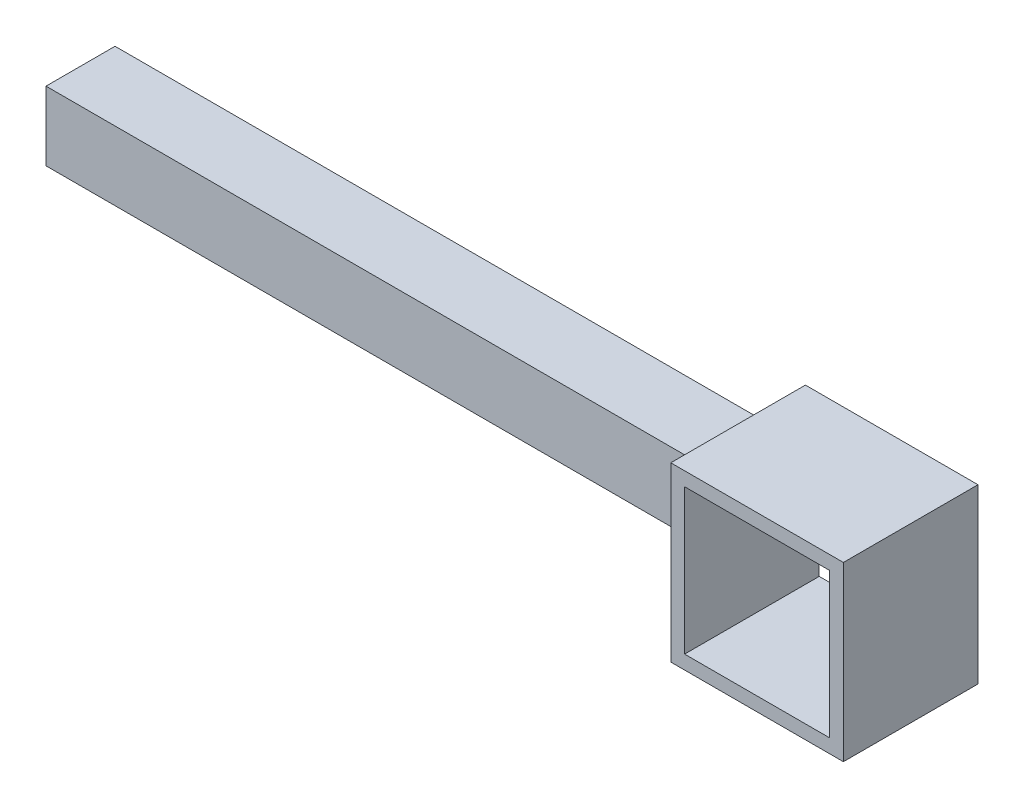
from build123d import *

# Parameters (mm, degrees)
ESQUISSE1_W             = 200
ESQUISSE1_H             = 20
ESQUISSE1_W_2           = 42
ESQUISSE1_H_2           = 42
BOSS_EXTRU_1_DEPTH      = 39
ESQUISSE2_W             = 200
ESQUISSE2_H             = 20
ENL_V_MAT_EXTRU_1_DEPTH = 19
ESQUISSE3_W             = 204
ESQUISSE3_H             = 10
ENL_V_MAT_EXTRU_3_DEPTH = 5


with BuildPart() as part:
    # Esquisse1 → Boss.-Extru.1 (new body)
    with BuildSketch(Plane.XY):
        with Locations((100, -10)):
            Rectangle(ESQUISSE1_W, ESQUISSE1_H)
        Polygon((200, 15), (200, 0), (200, -20), (200, -35), (250, -35), (250, 15), align=None)
        with Locations((225, -10)):
            Rectangle(ESQUISSE1_W_2, ESQUISSE1_H_2, mode=Mode.SUBTRACT)
    extrude(amount=BOSS_EXTRU_1_DEPTH)

    # Esquisse2 → Enlèv. mat.-Extru.1 (cut)
    with BuildSketch(Plane.XY.offset(39)):
        with Locations((100, -10)):
            Rectangle(ESQUISSE2_W, ESQUISSE2_H)
    extrude(amount=-ENL_V_MAT_EXTRU_1_DEPTH, mode=Mode.SUBTRACT)

    # Esquisse3 → Enlèv. mat.-Extru.3 (cut)
    with BuildSketch(Plane(origin=(0, 0, 0), x_dir=(-1, 0, 0), z_dir=(0, 0, -1))):
        with Locations((-102, -10)):
            Rectangle(ESQUISSE3_W, ESQUISSE3_H)
    extrude(amount=-ENL_V_MAT_EXTRU_3_DEPTH, mode=Mode.SUBTRACT)


solid = part.part
